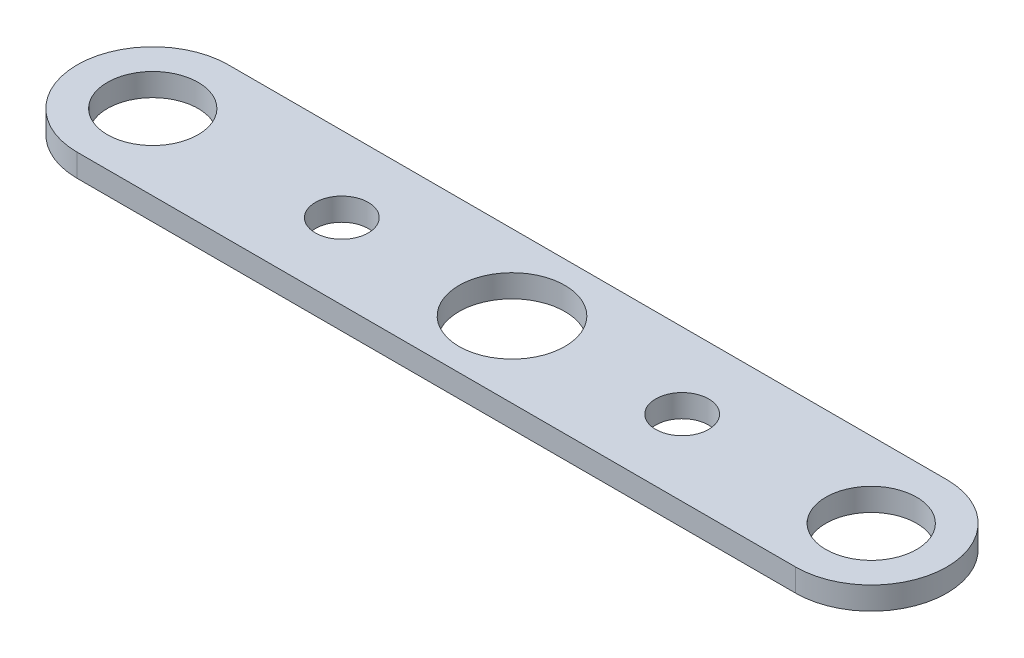
from build123d import *

# Parameters (mm, degrees)
SKETCH1_R           = 6
BOSS_EXTRUDE1_DEPTH = 3
SKETCH2_R           = 7
CUT_EXTRUDE1_DEPTH  = 4
SKETCH3_R           = 3.5
CUT_EXTRUDE2_DEPTH  = 4


with BuildPart() as part:
    # Sketch1 → Boss-Extrude1 (new body)
    with BuildSketch(Plane(origin=(0, 0, 0), x_dir=(1, 0, 0), z_dir=(0, 1, 0))):
        with BuildLine():
            Line((-7.092556659, 19.326923077), (87.907443341, 19.326923077))
            ThreePointArc((87.907443341, 19.326923077), (97.907443341, 9.326923077), (87.907443341, -0.673076923))
            Line((87.907443341, -0.673076923), (-7.092556659, -0.673076923))
            ThreePointArc((-7.092556659, -0.673076923), (-17.092556659, 9.326923077), (-7.092556659, 19.326923077))
        make_face()
        with Locations((-7.092556659, 9.326923077)):
            Circle(SKETCH1_R, mode=Mode.SUBTRACT)
        with Locations((87.907443341, 9.326923077)):
            Circle(SKETCH1_R, mode=Mode.SUBTRACT)
    extrude(amount=BOSS_EXTRUDE1_DEPTH)

    # Sketch2 → Cut-Extrude1 (cut, through all)
    with BuildSketch(Plane(origin=(0, 3, 0), x_dir=(1, 0, 0), z_dir=(0, 1, 0))):
        with Locations((40.407443341, 9.326923077)):
            Circle(SKETCH2_R)
    extrude(amount=-CUT_EXTRUDE1_DEPTH, mode=Mode.SUBTRACT)

    # Sketch3 → Cut-Extrude2 (cut, through all)
    with BuildSketch(Plane(origin=(0, 3, 0), x_dir=(1, 0, 0), z_dir=(0, 1, 0))):
        with Locations((17.907443341, 9.326923077)):
            Circle(SKETCH3_R)
        with Locations((62.907443341, 9.326923077)):
            Circle(SKETCH3_R)
    extrude(amount=-CUT_EXTRUDE2_DEPTH, mode=Mode.SUBTRACT)


solid = part.part
